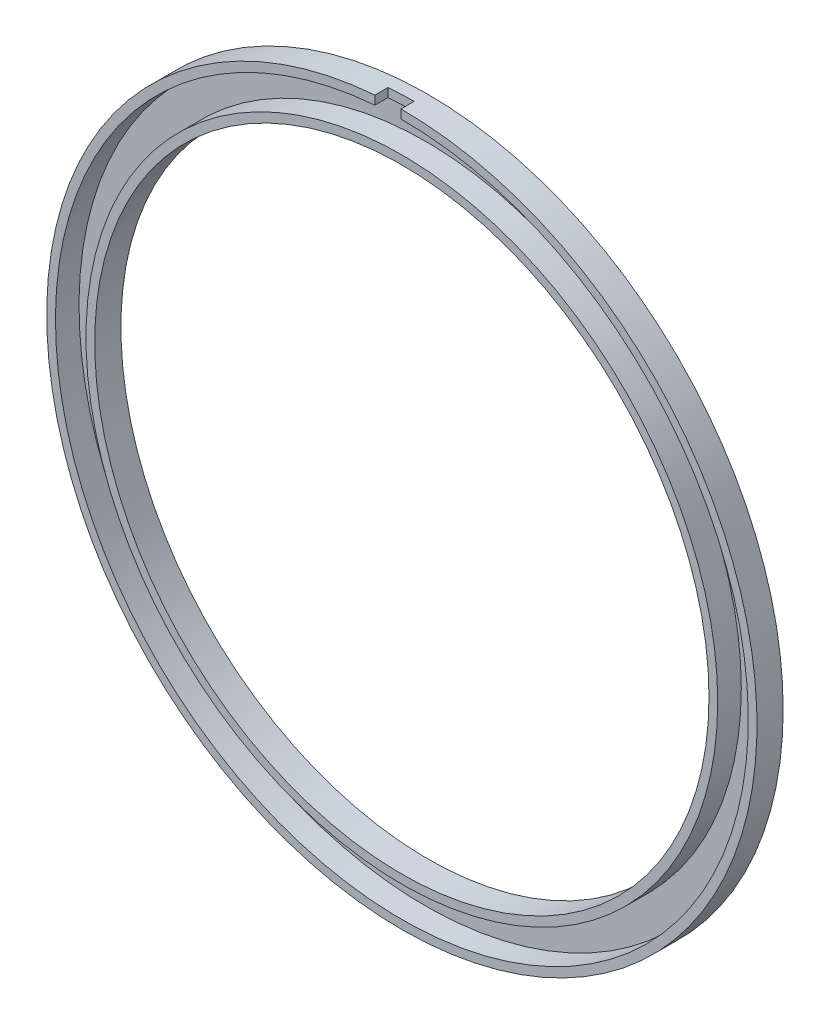
from build123d import *

# Parameters (mm, degrees)
SKETCH1_R           = 72.4
BOSS_EXTRUDE1_DEPTH = 0.6
SKETCH1_3_R         = 72.4
SKETCH1_3_R_2       = 70.4
BOSS_EXTRUDE2_DEPTH = 6
BOSS_EXTRUDE3_DEPTH = 3


with BuildPart() as part:
    # Sketch1 → Boss-Extrude1 (new body)
    with BuildSketch(Plane.XY):
        with BuildLine():
            ThreePointArc((-0.182652597, 79.399789912), (-3.184930452, 79.336096564), (-6.182652597, 79.158921208))
            ThreePointArc((-6.182652597, 79.158921208), (-53.91408621, -58.289204044), (79.4, 0))
            ThreePointArc((79.4, 0), (56.0796638, 56.208818775), (-0.182652597, 79.399789912))
        make_face()
        Circle(SKETCH1_R, mode=Mode.SUBTRACT)
    extrude(amount=BOSS_EXTRUDE1_DEPTH)

    # Sketch1_3 → Boss-Extrude2 (add)
    # profile 1 of 2: a face of its own
    with BuildSketch(Plane.XY):
        with BuildLine():
            Line((-6.182652597, 79.158921208), (-6.182652597, 81.164861898))
            ThreePointArc((-6.182652597, 81.164861898), (3.187118264, -81.337582194), (-0.187253418, 81.39978462))
            Line((-0.187253418, 81.39978462), (-0.182652597, 79.399789912))
            ThreePointArc((-0.182652597, 79.399789912), (3.184930452, -79.336096564), (-6.182652597, 79.158921208))
        make_face()
    # profile 2 of 2: a face of its own
    with BuildSketch(Plane.XY):
        Circle(SKETCH1_3_R)
        Circle(SKETCH1_3_R_2, mode=Mode.SUBTRACT)
    extrude(amount=BOSS_EXTRUDE2_DEPTH)

    # Sketch1_4 → Boss-Extrude3 (add)
    with BuildSketch(Plane.XY):
        with BuildLine():
            ThreePointArc((-0.187253418, 81.39978462), (-3.187118264, 81.337582194), (-6.182652597, 81.164861898))
            Line((-6.182652597, 81.164861898), (-6.182652597, 79.158921208))
            ThreePointArc((-6.182652597, 79.158921208), (-3.184930452, 79.336096564), (-0.182652597, 79.399789912))
            Line((-0.182652597, 79.399789912), (-0.187253418, 81.39978462))
        make_face()
    extrude(amount=BOSS_EXTRUDE3_DEPTH)


solid = part.part
